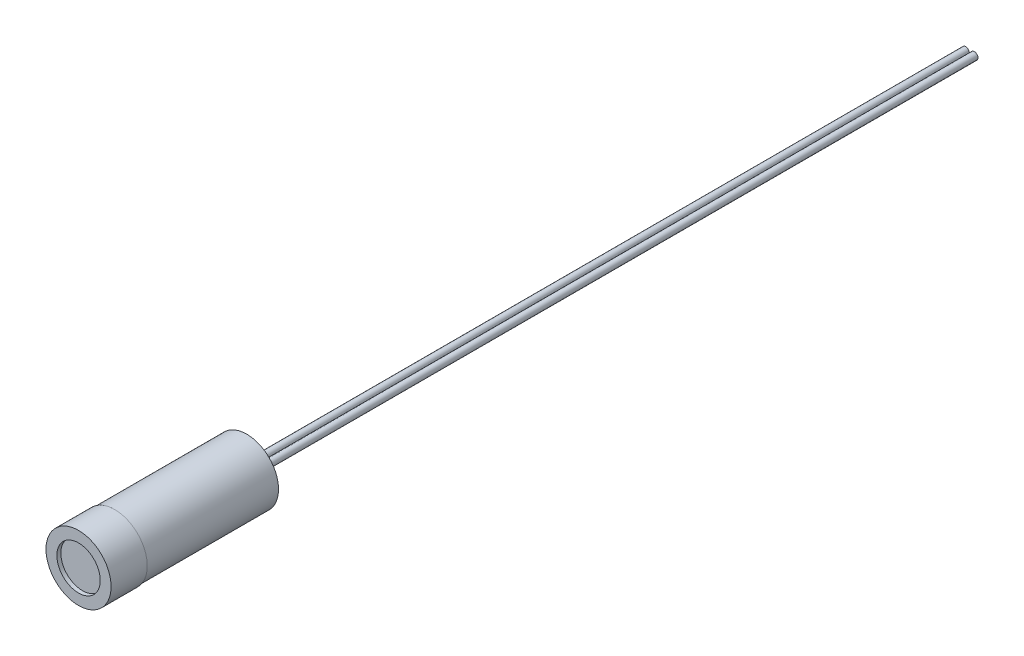
from build123d import *

# Parameters (mm, degrees)
SKETCH2_R           = 0.5
BOSS_EXTRUDE1_DEPTH = 100


with BuildPart() as part:
    # Sketch1 → Revolve1 (revolve)
    with BuildSketch(Plane(origin=(0, 0, 0), x_dir=(0, 0, -1), z_dir=(1, 0, 0)), mode=Mode.PRIVATE) as revolve1_sk:
        Polygon((0, 4.5), (0, 3), (0.55, 3), (0.55, 0), (23.25, 0), (23.25, 4.4), (5, 4.4), (5, 4.5), align=None)
    revolve(revolve1_sk.sketch.rotate(Axis((0, 0, 0), (0, 0, 1)), 90), axis=Axis((0, 0, 0), (0, 0, 1)))  # turned: the seam where the file's is

    # Sketch2 → Boss-Extrude1 (add)
    with BuildSketch(Plane(origin=(0, 0, -23.25), x_dir=(-1, 0, 0), z_dir=(0, 0, -1))):
        with Locations((-0.6, 0)):
            Circle(SKETCH2_R)
    boss_extrude1 = extrude(amount=BOSS_EXTRUDE1_DEPTH)

    # Mirror1: Boss-Extrude1 across plane
    add(boss_extrude1.mirror(Plane(origin=(0, 0, 0), x_dir=(0, 0, 1), z_dir=(1, 0, 0))))


solid = part.part
